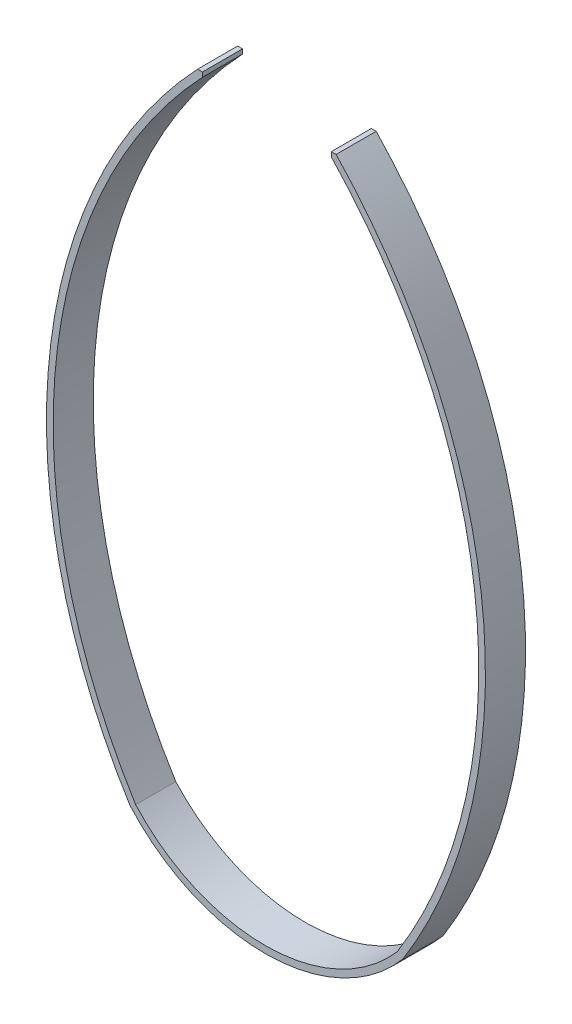
from build123d import *

# Parameters (mm, degrees)
BOSS_EXTRU_1_DEPTH = 30


with BuildPart() as part:
    # Esquisse1 → Boss.-Extru.1 (new body)
    with BuildSketch(Plane.XY):
        with BuildLine():
            Line((46.368433326, 259.570837519), (46.368433326, 263.007656324))
            Line((46.368433326, 263.007656324), (50, 263.007656324))
            ThreePointArc((50, 263.007656324), (159.652687148, 23.346633699), (99.977310085, -233.363254962))
            ThreePointArc((99.977310085, -233.363254962), (-1.517561323, -281.361033685), (-104.221114809, -236.007138747))
            ThreePointArc((-104.221114809, -236.007138747), (-164.627534347, 23.847528243), (-53.631566674, 266.444475128))
            Line((-53.631566674, 266.444475128), (-50, 266.444475128))
            Line((-50, 266.444475128), (-50, 263.007656324))
            ThreePointArc((-50, 263.007656324), (-159.652687148, 23.346633699), (-99.977310085, -233.363254962))
            ThreePointArc((-99.977310085, -233.363254962), (-1.526330683, -276.127902533), (95.733505362, -230.719371177))
            ThreePointArc((95.733505362, -230.719371177), (154.677839949, 22.845739156), (46.368433326, 259.570837519))
        make_face()
    extrude(amount=BOSS_EXTRU_1_DEPTH)


solid = part.part
